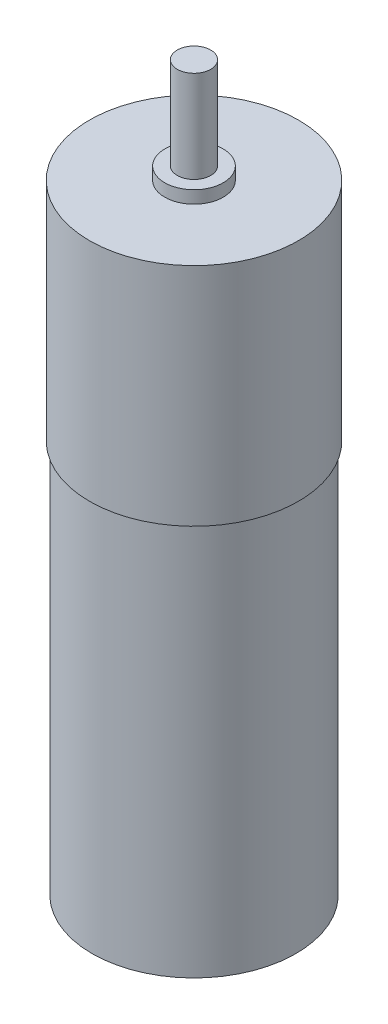
from build123d import *

# Parameters (mm, degrees)
SKETCH1_R           = 12.2
BOSS_EXTRUDE1_DEPTH = 23.5
SKETCH2_R           = 12.5
BOSS_EXTRUDE2_DEPTH = 27
SKETCH3_R           = 3.5
BOSS_EXTRUDE3_DEPTH = 1.5
SKETCH4_R           = 2
BOSS_EXTRUDE4_DEPTH = 11


with BuildPart() as part:
    # Sketch1 → Boss-Extrude1 (new body, symmetric)
    with BuildSketch(Plane(origin=(0, 0, 0), x_dir=(1, 0, 0), z_dir=(0, 1, 0))):
        Circle(SKETCH1_R)
    extrude(amount=BOSS_EXTRUDE1_DEPTH, both=True)

    # Sketch2 → Boss-Extrude2 (add)
    with BuildSketch(Plane(origin=(0, 23.5, 0), x_dir=(1, 0, 0), z_dir=(0, 1, 0))):
        Circle(SKETCH2_R)
    extrude(amount=BOSS_EXTRUDE2_DEPTH)

    # Sketch3 → Boss-Extrude3 (add)
    with BuildSketch(Plane(origin=(0, 50.5, 0), x_dir=(1, 0, 0), z_dir=(0, 1, 0))):
        Circle(SKETCH3_R)
    extrude(amount=BOSS_EXTRUDE3_DEPTH)

    # Sketch4 → Boss-Extrude4 (add)
    with BuildSketch(Plane(origin=(0, 52, 0), x_dir=(1, 0, 0), z_dir=(0, 1, 0))):
        Circle(SKETCH4_R)
    extrude(amount=BOSS_EXTRUDE4_DEPTH)


solid = part.part
